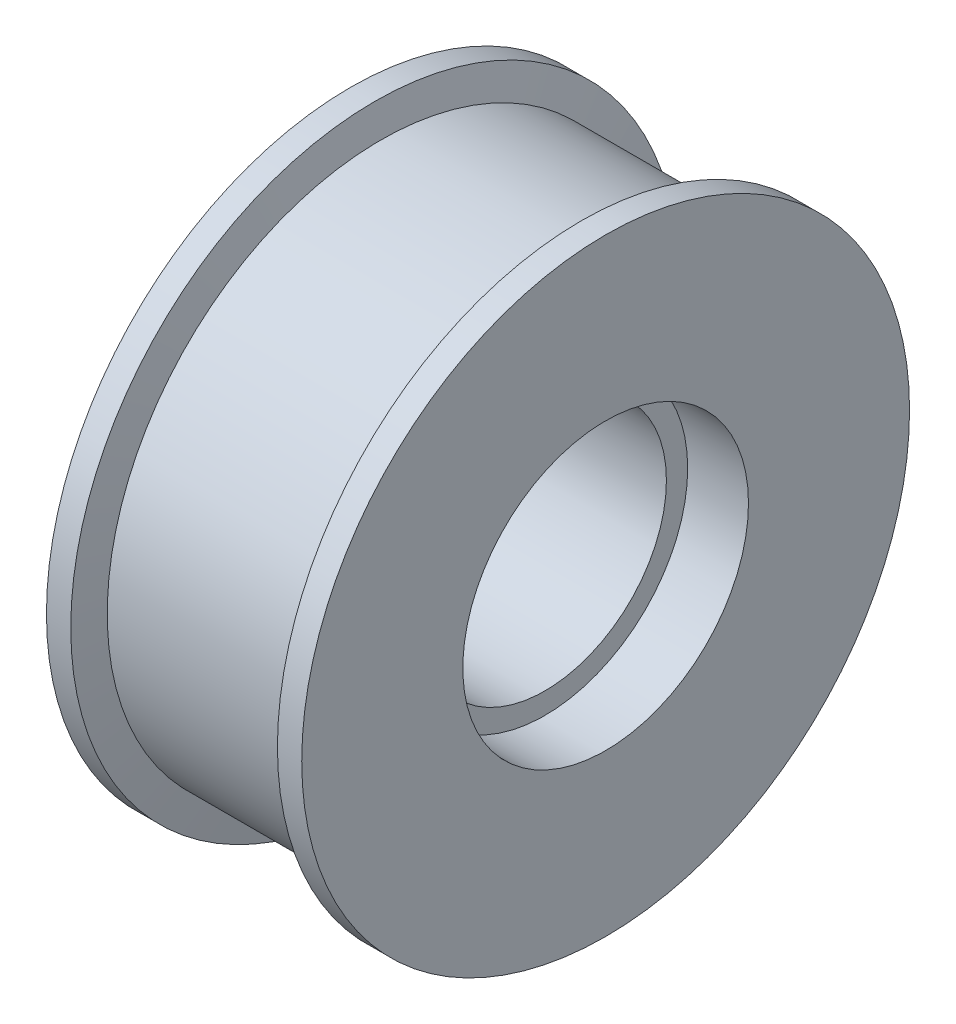
from build123d import *


with BuildPart() as part:
    # 草图1 → 旋转1 (revolve)
    with BuildSketch(Plane(origin=(0, -730.369166709, 693.602190087), x_dir=(-1, 0, 0), z_dir=(0, -0.725122626, 0.688619762))):
        Polygon((-32.892369562, 64.467253591), (-32.892369562, 90.967253591), (-28.892369562, 90.967253591), (-27.892369562, 85.967253591), (4.107630438, 85.967253591), (5.107630438, 90.967253591), (9.107630438, 90.967253591), (9.107630438, 64.467253591), (-0.892369562, 64.467253591), (-0.892369562, 60.967253591), (-22.892369562, 60.967253591), (-22.892369562, 64.467253591), align=None)
    revolve(axis=Axis((43.903105844, -758.580027128, 663.895907566), (-1, 0, 0)))


solid = part.part
